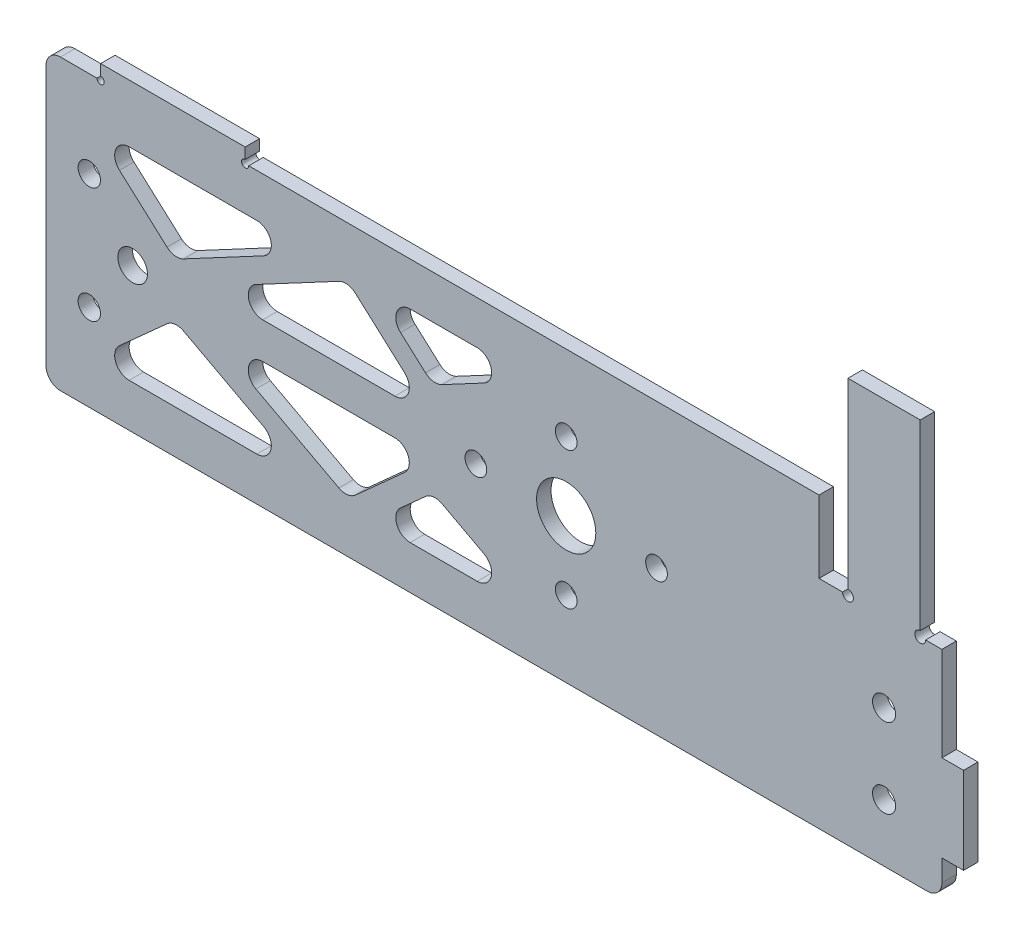
from build123d import *

# Parameters (mm, degrees)
EXTRUDE_1_DEPTH      = 2
SKETCH_2_R           = 1.6
CUT_EXTRUDE_1_DEPTH  = 3
SKETCH_3_W           = 3
SKETCH_3_H           = 24
SKETCH_3_W_2         = 4
CUT_EXTRUDE_2_DEPTH  = 3
SKETCH_4_W           = 3
SKETCH_4_H           = 12
CUT_EXTRUDE_3_DEPTH  = 3
SKETCH_5_W           = 83
SKETCH_5_H           = 30
EXTRUDE_2_DEPTH      = 2
SKETCH_6_R           = 4.1
CUT_EXTRUDE_4_DEPTH  = 3
SKETCH_7_W           = 83
SKETCH_7_H           = 10
EXTRUDE_4_DEPTH      = 2
SKETCH_8_R           = 1.5
CUT_EXTRUDE_5_DEPTH  = 10
SKETCH_13_W          = 2
SKETCH_13_H          = 40
EXTRUDE_6_DEPTH      = 24
SKETCH_16_R          = 0.75
CUT_EXTRUDE_9_DEPTH  = 3
SKETCH_17_W          = 10
SKETCH_17_H          = 2
EXTRUDE_8_DEPTH      = 2
SKETCH_18_W          = 20
SKETCH_18_H          = 2
EXTRUDE_9_DEPTH      = 2
SKETCH_19_R          = 1.55
SKETCH_19_R_2        = 2.05
CUT_EXTRUDE_10_DEPTH = 10
FILLET_1_R           = 2
CUT_EXTRUDE_11_DEPTH = 10
FILLET_2_R           = 2
SKETCH_22_W          = 3
SKETCH_22_H          = 12
EXTRUDE_10_DEPTH     = 2
SKETCH_23_R          = 0.5
CUT_EXTRUDE_12_DEPTH = 10


with BuildPart() as part:
    # 草图1 → 凸台-拉伸1 (new body)
    with BuildSketch(Plane.XY):
        Polygon((0, 0), (17, 0), (17, 5), (20, 5), (20, 17), (17, 17), (17, 54), (0, 54), align=None)
    extrude(amount=EXTRUDE_1_DEPTH)

    # 草图2 → 切除-拉伸1 (cut, through all)
    with BuildSketch(Plane.XY.offset(2)):
        with Locations((9, 8)):
            Circle(SKETCH_2_R)
        with Locations((9, 19)):
            Circle(SKETCH_2_R)
    extrude(amount=-CUT_EXTRUDE_1_DEPTH, mode=Mode.SUBTRACT)

    # 草图3 → 切除-拉伸2 (cut, through all)
    with BuildSketch(Plane.XY.offset(2)):
        with Locations((15.5, 42)):
            Rectangle(SKETCH_3_W, SKETCH_3_H)
        with Locations((2, 42)):
            Rectangle(SKETCH_3_W_2, SKETCH_3_H)
    extrude(amount=-CUT_EXTRUDE_2_DEPTH, mode=Mode.SUBTRACT)

    # 草图4 → 切除-拉伸3 (cut, through all)
    with BuildSketch(Plane.XY.offset(2)):
        with Locations((18.5, 11)):
            Rectangle(SKETCH_4_W, SKETCH_4_H)
    extrude(amount=-CUT_EXTRUDE_3_DEPTH, mode=Mode.SUBTRACT)

    # 草图5 → 凸台-拉伸2 (add, through all)
    with BuildSketch(Plane.XY.offset(2)):
        with Locations((-41.5, 15)):
            Rectangle(SKETCH_5_W, SKETCH_5_H)
    extrude(amount=-EXTRUDE_2_DEPTH)

    # 草图6 → 切除-拉伸4 (cut, through all)
    with BuildSketch(Plane.XY.offset(2)):
        with Locations((-35, 20)):
            Circle(SKETCH_6_R)
    extrude(amount=-CUT_EXTRUDE_4_DEPTH, mode=Mode.SUBTRACT)

    # 草图7 → 凸台-拉伸4 (add, through all)
    with BuildSketch(Plane.XY.offset(2)):
        with Locations((-41.5, 35)):
            Rectangle(SKETCH_7_W, SKETCH_7_H)
    extrude(amount=-EXTRUDE_4_DEPTH)

    # 草图8 → 切除-拉伸5 (cut)
    with BuildSketch(Plane.XY.offset(2)):
        with Locations((-35, 29.5)):
            Circle(SKETCH_8_R)
        with Locations((-35, 10.5)):
            Circle(SKETCH_8_R)
        with Locations((-47.5, 20)):
            Circle(SKETCH_8_R)
        with Locations((-22.5, 20)):
            Circle(SKETCH_8_R)
    extrude(amount=-CUT_EXTRUDE_5_DEPTH, mode=Mode.SUBTRACT)

    # 草图13 → 凸台-拉伸6 (add)
    with BuildSketch(Plane.ZY.offset(83)):
        with Locations((1, 20)):
            Rectangle(SKETCH_13_W, SKETCH_13_H)
    extrude(amount=EXTRUDE_6_DEPTH)

    # 草图16 → 切除-拉伸9 (cut)
    with BuildSketch(Plane(origin=(0, 0, 0), x_dir=(-1, 0, 0), z_dir=(0, 0, -1))):
        with Locations((-4, 30)):
            Circle(SKETCH_16_R)
        with Locations((-14, 30)):
            Circle(SKETCH_16_R)
    extrude(amount=-CUT_EXTRUDE_9_DEPTH, mode=Mode.SUBTRACT)

    # 草图17 → 凸台-拉伸8 (add)
    with BuildSketch(Plane(origin=(0, 54, 0), x_dir=(1, 0, 0), z_dir=(0, 1, 0))):
        with Locations((9, -1)):
            Rectangle(SKETCH_17_W, SKETCH_17_H)
    extrude(amount=EXTRUDE_8_DEPTH)

    # 草图18 → 凸台-拉伸9 (add)
    with BuildSketch(Plane.XY.offset(2)):
        with Locations((-89.439408026, 41)):
            Rectangle(SKETCH_18_W, SKETCH_18_H)
    extrude(amount=-EXTRUDE_9_DEPTH)

    # 草图19 → 切除-拉伸10 (cut)
    with BuildSketch(Plane.XY.offset(2)):
        with Locations((-101.009408026, 12)):
            Circle(SKETCH_19_R)
        with Locations((-101.009408026, 28)):
            Circle(SKETCH_19_R)
        with Locations((-95.009408026, 20)):
            Circle(SKETCH_19_R_2)
    extrude(amount=-CUT_EXTRUDE_10_DEPTH, mode=Mode.SUBTRACT)

    # 圆角1
    fillet_1_edges = [part.edges().sort_by_distance(p)[0] for p in [
        (-107, 0, 1),
        (-107, 40, 1),
        (17, 0, 1),
    ]]
    fillet(fillet_1_edges, radius=FILLET_1_R)

    # 草图21 → 切除-拉伸11 (cut)
    with BuildSketch(Plane(origin=(0, 0, 0), x_dir=(-1, 0, 0), z_dir=(0, 0, -1))):
        Polygon((100.712510242, 6), (89.209450959, 16.338708626), (69.80722773, 6), align=None)
        Polygon((65.227917011, 6.959193961), (85.009408026, 17.5), (53.5, 17.5), align=None)
        Polygon((61.80722773, 6), (53.43509819, 13.524694584), (39.313817735, 6), align=None)
        Polygon((53.43509819, 26.475305416), (39.313817735, 34), (61.80722773, 34), align=None)
        Polygon((85.009408026, 22.5), (53.5, 22.5), (65.227917011, 33.040806039), align=None)
        Polygon((89.209450959, 23.661291374), (69.80722773, 34), (100.712510242, 34), align=None)
    extrude(amount=-CUT_EXTRUDE_11_DEPTH, mode=Mode.SUBTRACT)

    # 圆角2
    fillet_2_edges = [part.edges().sort_by_distance(p)[0] for p in [
        (-61.80722773, 6, 1),
        (-39.313817735, 6, 1),
        (-53.43509819, 13.524694584, 1),
        (-65.227917011, 6.959193961, 1),
        (-53.5, 17.5, 1),
        (-85.009408026, 17.5, 1),
        (-65.227917011, 33.040806039, 1),
        (-85.009408026, 22.5, 1),
        (-53.5, 22.5, 1),
        (-61.80722773, 34, 1),
        (-53.43509819, 26.475305416, 1),
        (-39.313817735, 34, 1),
        (-100.712510242, 34, 1),
        (-89.209450959, 23.661291374, 1),
        (-69.80722773, 34, 1),
        (-100.712510242, 6, 1),
        (-69.80722773, 6, 1),
        (-89.209450959, 16.338708626, 1),
    ]]
    fillet(fillet_2_edges, radius=FILLET_2_R)

    # 草图22 → 凸台-拉伸10 (add)
    with BuildSketch(Plane.XY.offset(2)):
        with Locations((18.5, 11)):
            Rectangle(SKETCH_22_W, SKETCH_22_H)
    extrude(amount=-EXTRUDE_10_DEPTH)

    # 草图23 → 切除-拉伸12 (cut)
    with BuildSketch(Plane.XY.offset(2)):
        with Locations((-79.439408026, 40)):
            Circle(SKETCH_23_R)
        with Locations((-99.439408026, 40)):
            Circle(SKETCH_23_R)
    extrude(amount=-CUT_EXTRUDE_12_DEPTH, mode=Mode.SUBTRACT)


solid = part.part
